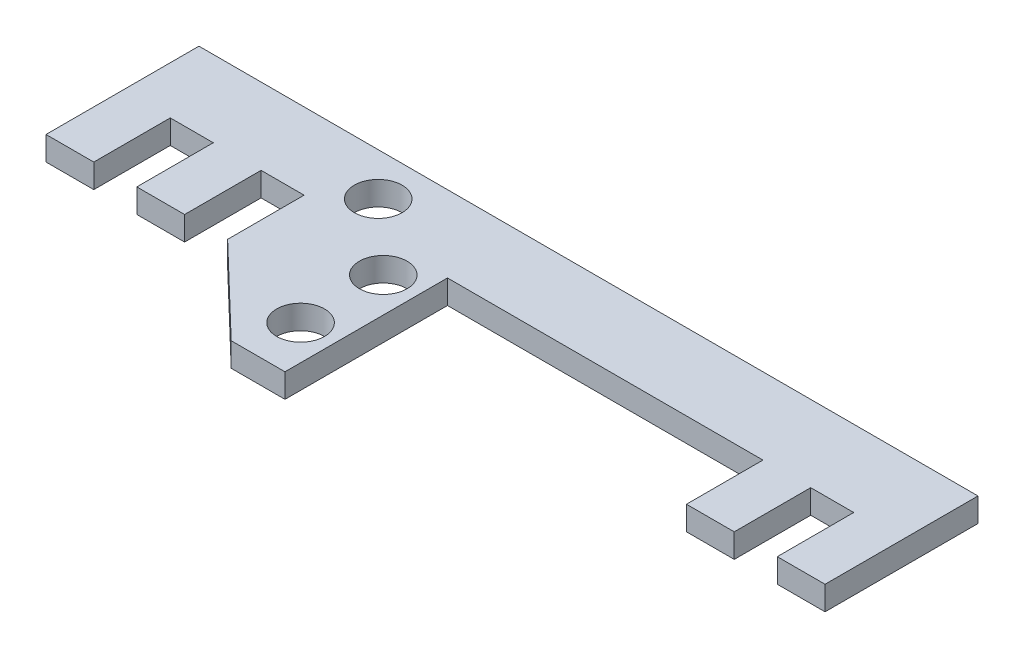
from build123d import *

# Parameters (mm, degrees)
BOSS_EXTRUDE1_DEPTH = 1
CUT_EXTRUDE1_REACH  = 3
SKETCH2_R           = 1


with BuildPart() as part:
    # Sketch1 → Boss-Extrude1 (new body)
    with BuildSketch(Plane(origin=(0, 0, 0), x_dir=(1, 0, 0), z_dir=(0, 1, 0))):
        Polygon((0, 0), (0, 6.4), (32.6, 6.4), (32.6, 0), (30.6, 0), (30.6, 3.2), (28.8, 3.2), (28.8, 0), (26.8, 0), (26.8, 3.2), (13.6, 3.2), (13.6, -3.6), (11.35, -3.6), (7.6, 0), (7.6, 3.2), (5.8, 3.2), (5.8, 0), (3.8, 0), (3.8, 3.2), (2, 3.2), (2, 0), align=None)
    extrude(amount=BOSS_EXTRUDE1_DEPTH)

    # Sketch2 → Cut-Extrude1 (cut, up to next)
    with BuildSketch(Plane(origin=(0, 1, 0), x_dir=(1, 0, 0), z_dir=(0, 1, 0)), mode=Mode.PRIVATE) as cut_extrude1_sk1:
        with Locations((9.286488836, 4.615010183)):
            Circle(SKETCH2_R)
    cut_extrude1_tool1 = extrude(cut_extrude1_sk1.sketch, amount=-CUT_EXTRUDE1_REACH, mode=Mode.PRIVATE) & part.part
    add(cut_extrude1_tool1.solids().sort_by_distance((9.286489, 1, -4.61501))[0], mode=Mode.SUBTRACT)
    # Sketch2 → Cut-Extrude1 (cut, up to next)
    with BuildSketch(Plane(origin=(0, 1, 0), x_dir=(1, 0, 0), z_dir=(0, 1, 0)), mode=Mode.PRIVATE) as cut_extrude1_sk2:
        with Locations((12.147825288, 1.964747252)):
            Circle(SKETCH2_R)
    cut_extrude1_tool2 = extrude(cut_extrude1_sk2.sketch, amount=-CUT_EXTRUDE1_REACH, mode=Mode.PRIVATE) & part.part
    add(cut_extrude1_tool2.solids().sort_by_distance((12.147825, 1, -1.964747))[0], mode=Mode.SUBTRACT)
    # Sketch2 → Cut-Extrude1 (cut, up to next)
    with BuildSketch(Plane(origin=(0, 1, 0), x_dir=(1, 0, 0), z_dir=(0, 1, 0)), mode=Mode.PRIVATE) as cut_extrude1_sk3:
        with Locations((12.147825288, -1.494058873)):
            Circle(SKETCH2_R)
    cut_extrude1_tool3 = extrude(cut_extrude1_sk3.sketch, amount=-CUT_EXTRUDE1_REACH, mode=Mode.PRIVATE) & part.part
    add(cut_extrude1_tool3.solids().sort_by_distance((12.147825, 1, 1.494059))[0], mode=Mode.SUBTRACT)


solid = part.part
